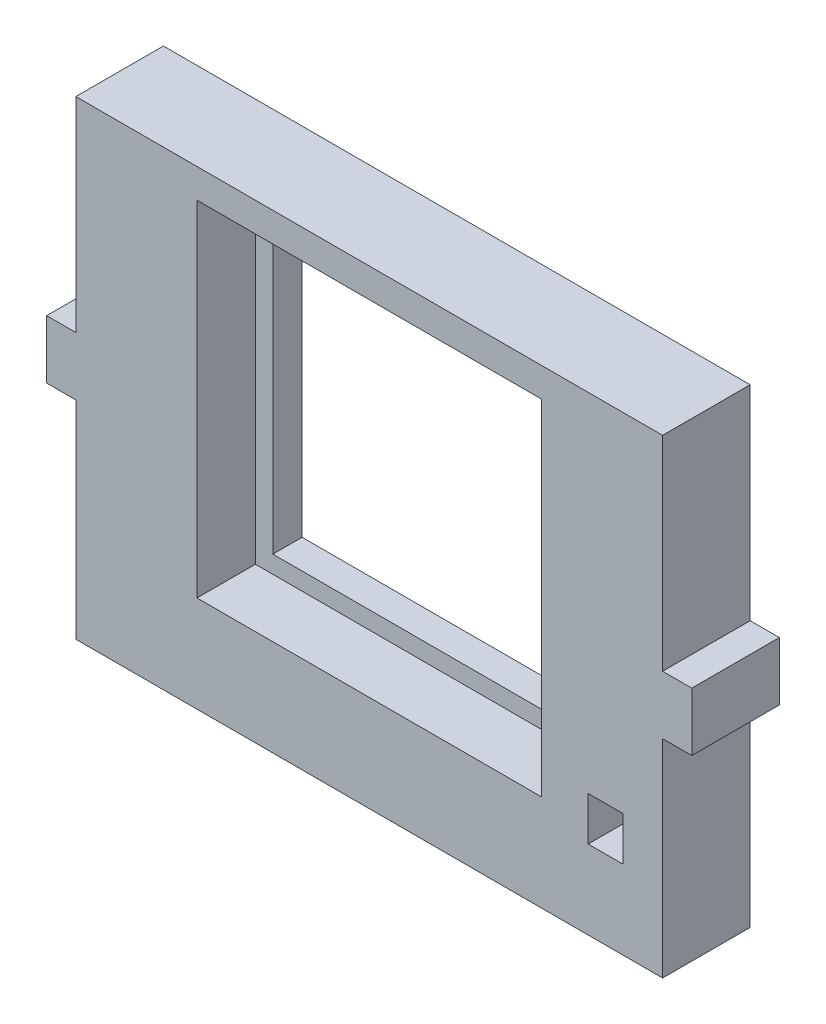
from build123d import *

# Parameters (mm, degrees)
SKETCH_1_W          = 5
SKETCH_1_H          = 10
SKETCH_1_W_2        = 100.5
SKETCH_1_H_2        = 80.5
SKETCH_1_W_3        = 6
SKETCH_1_H_3        = 7.5
SKETCH_1_W_4        = 53
SKETCH_1_H_4        = 53
EXTRUDE_1_DEPTH     = 15
SKETCH_2_W          = 59
SKETCH_2_H          = 59
CUT_EXTRUDE_1_DEPTH = 10


with BuildPart() as part:
    # 草圖1 → 填料-伸長1 (new body)
    with BuildSketch(Plane.XY):
        with Locations((-62.305536773, -5.054)):
            Rectangle(SKETCH_1_W, SKETCH_1_H)
        with Locations((-9.555536773, -5.304)):
            Rectangle(SKETCH_1_W_2, SKETCH_1_H_2)
        with Locations((30.944463227, -28.304)):
            Rectangle(SKETCH_1_W_3, SKETCH_1_H_3, mode=Mode.SUBTRACT)
        with Locations((-9.555536773, 0.446)):
            Rectangle(SKETCH_1_W_4, SKETCH_1_H_4, mode=Mode.SUBTRACT)
        with Locations((43.194463227, -5.054)):
            Rectangle(SKETCH_1_W, SKETCH_1_H)
    extrude(amount=EXTRUDE_1_DEPTH)

    # 草圖2 → 除料-伸長1 (cut)
    with BuildSketch(Plane.XY.offset(15)):
        with Locations((-9.555536773, 0.446)):
            Rectangle(SKETCH_2_W, SKETCH_2_H)
    extrude(amount=-CUT_EXTRUDE_1_DEPTH, mode=Mode.SUBTRACT)


solid = part.part
